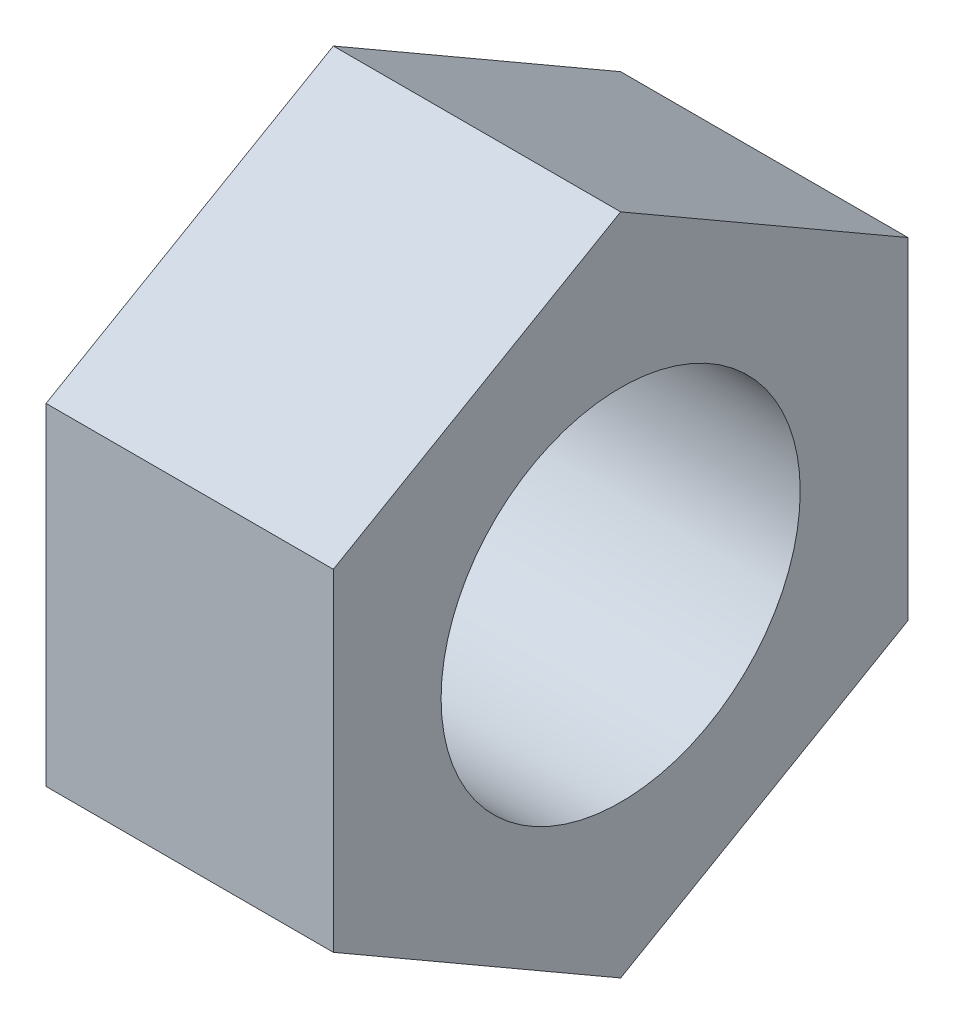
from build123d import *

# Parameters (mm, degrees)
SKETCH1_R           = 3.96875
BOSS_EXTRUDE1_DEPTH = 6.35


with BuildPart() as part:
    # Sketch1 → Boss-Extrude1 (new body)
    with BuildSketch(Plane(origin=(0, 0, 0), x_dir=(0, 0, -1), z_dir=(1, 0, 0))):
        Polygon((0, 7.332348419), (-6.35, 3.666174209), (-6.35, -3.666174209), (0, -7.332348419), (6.35, -3.666174209), (6.35, 3.666174209), align=None)
        Circle(SKETCH1_R, mode=Mode.SUBTRACT)
    extrude(amount=BOSS_EXTRUDE1_DEPTH)


solid = part.part
